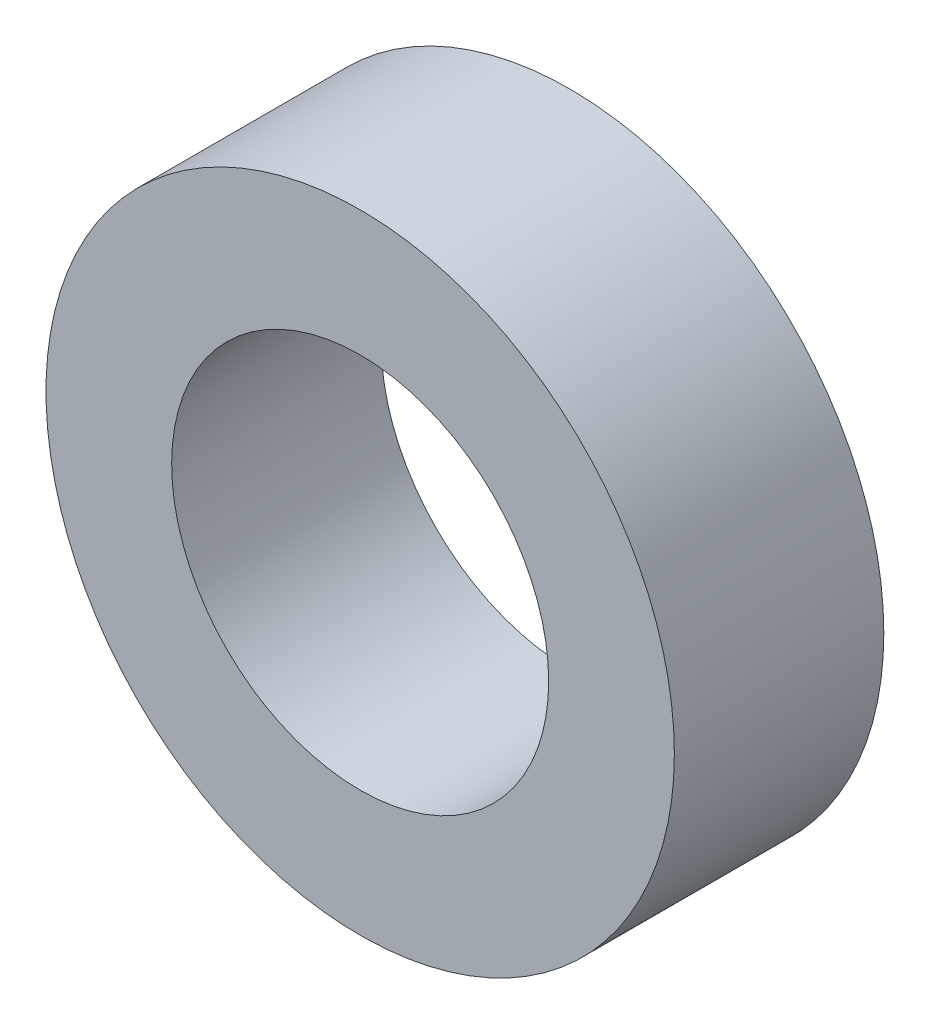
from build123d import *

# Parameters (mm, degrees)
SKETCH1_R           = 15
SKETCH1_R_2         = 9
BOSS_EXTRUDE1_DEPTH = 5


with BuildPart() as part:
    # Sketch1 → Boss-Extrude1 (new body, symmetric)
    with BuildSketch(Plane.XY):
        Circle(SKETCH1_R)
        Circle(SKETCH1_R_2, mode=Mode.SUBTRACT)
    extrude(amount=BOSS_EXTRUDE1_DEPTH, both=True)


solid = part.part
